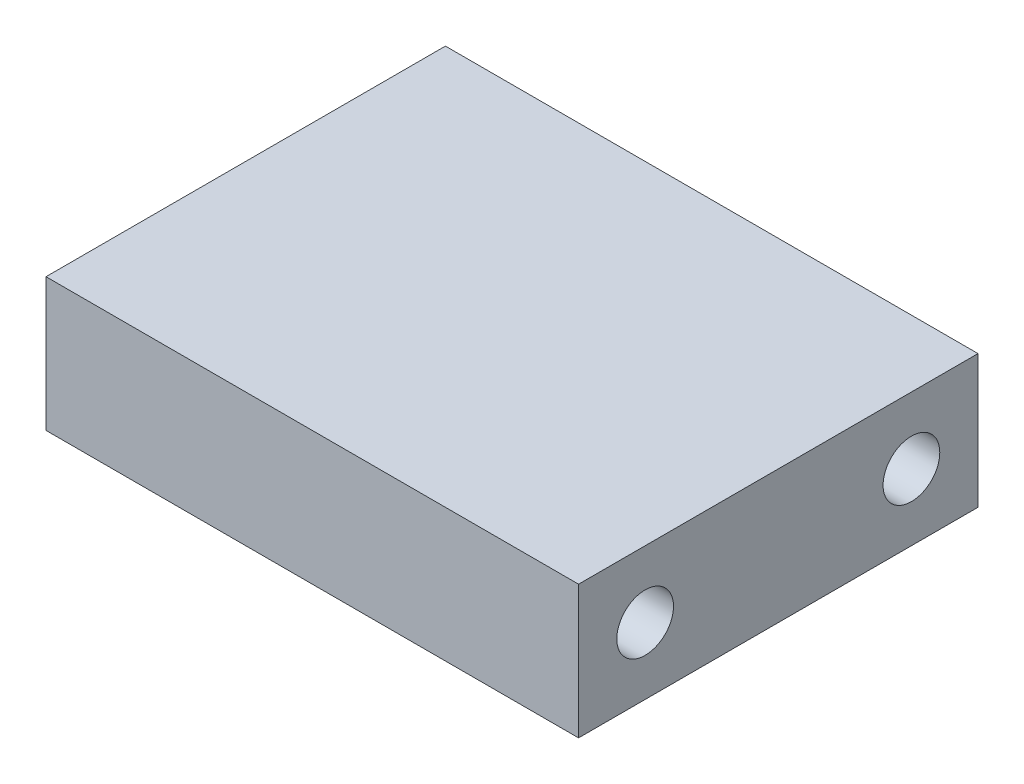
from build123d import *

# Parameters (mm, degrees)
SKETCH1_W                  = 25.4
SKETCH1_H                  = 19.05
EXTRUDE1_DEPTH             = 6.35
TAP_DRILL_FOR_6_TAP1_D     = 2.7051
TAP_DRILL_FOR_6_TAP1_DEPTH = 12.7
TAP_DRILL_FOR_6_TAP1_TIP   = 0.81269403


with BuildPart() as part:
    # Sketch1 → Extrude1 (new body)
    with BuildSketch(Plane(origin=(0, 0, 0), x_dir=(1, 0, 0), z_dir=(0, 1, 0))):
        Rectangle(SKETCH1_W, SKETCH1_H)
    extrude(amount=EXTRUDE1_DEPTH)

    # Tap Drill for #6 Tap1
    with Locations(Plane(origin=(12.7, 3.175, 6.35), x_dir=(0, 0, 1), z_dir=(1, 0, 0))):
        with Locations((0, 0), (-12.7, 0)):
            Hole(TAP_DRILL_FOR_6_TAP1_D / 2, depth=TAP_DRILL_FOR_6_TAP1_DEPTH)
            with Locations((0, 0, -(TAP_DRILL_FOR_6_TAP1_DEPTH + TAP_DRILL_FOR_6_TAP1_TIP / 2))):  # 118° drill point
                Cone(0, TAP_DRILL_FOR_6_TAP1_D / 2, TAP_DRILL_FOR_6_TAP1_TIP, mode=Mode.SUBTRACT)


solid = part.part
